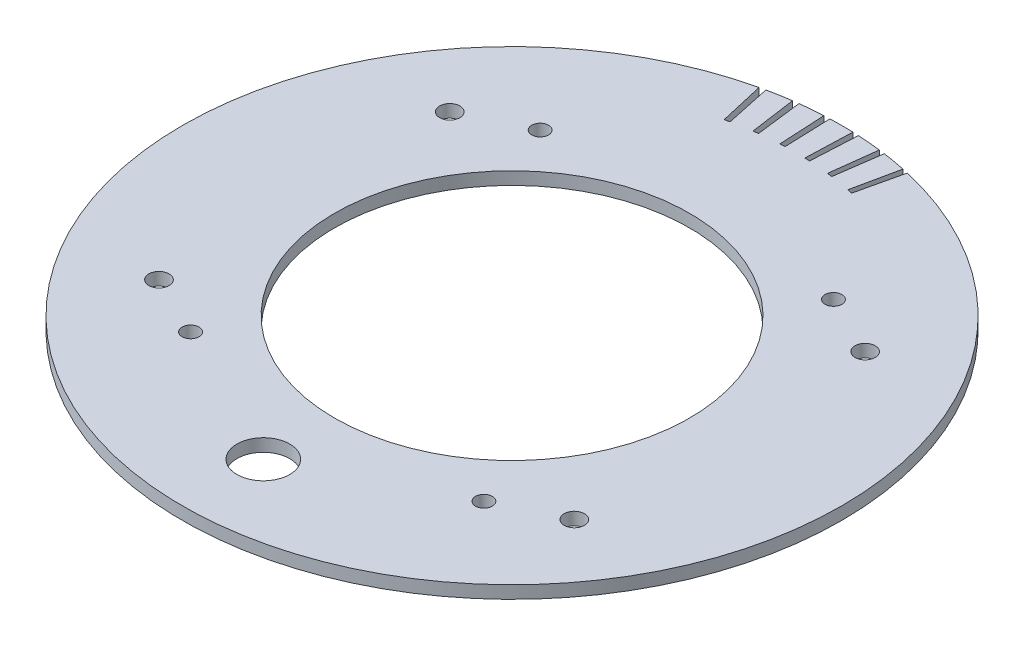
from build123d import *

# Parameters (mm, degrees)
F_98MM_6ID_CENTERING_RING_SKETCH_R = 53.34
CENTERING_RING_EXTRUDE_DEPTH       = 1.905
CENTERING_RING_EXTRUDE_DEPTH_BACK  = 1.905
CUT_EXTRUDE3_DEPTH                 = 4.81
CIRPATTERN1_COUNT                  = 6
CIRPATTERN1_ANGLE                  = 25
SKETCH5_R                          = 3.048
SKETCH5_R_2                        = 2.54
SKETCH5_R_3                        = 7.9375
CUT_EXTRUDE4_DEPTH                 = 3.81


with BuildPart() as part:
    # 98mm - 6ID centering ring sketch → Centering Ring Extrude (new body, two sides)
    with BuildSketch(Plane(origin=(0, 0, 0), x_dir=(1, 0, 0), z_dir=(0, 1, 0))) as centering_ring_extrude_sk:
        with BuildLine():
            Line((56.425744124, 3.175), (99.009105516, 3.175))
            ThreePointArc((99.009105516, 3.175), (70.045997744, 70.045997744), (3.175, 99.009105516))
            Line((3.175, 99.009105516), (3.175, 56.425744124))
            ThreePointArc((3.175, 56.425744124), (0, 56.515), (-3.175, 56.425744124))
            Line((-3.175, 56.425744124), (-3.175, 99.009105516))
            ThreePointArc((-3.175, 99.009105516), (-70.045997744, 70.045997744), (-99.009105516, 3.175))
            Line((-99.009105516, 3.175), (-56.425744124, 3.175))
            ThreePointArc((-56.425744124, 3.175), (-56.515, 0), (-56.425744124, -3.175))
            Line((-56.425744124, -3.175), (-99.009105516, -3.175))
            ThreePointArc((-99.009105516, -3.175), (-70.045997744, -70.045997744), (-3.175, -99.009105516))
            Line((-3.175, -99.009105516), (-3.175, -56.425744124))
            ThreePointArc((-3.175, -56.425744124), (0, -56.515), (3.175, -56.425744124))
            Line((3.175, -56.425744124), (3.175, -99.009105516))
            ThreePointArc((3.175, -99.009105516), (70.045997744, -70.045997744), (99.009105516, -3.175))
            Line((99.009105516, -3.175), (56.425744124, -3.175))
            ThreePointArc((56.425744124, -3.175), (56.515, 0), (56.425744124, 3.175))
        make_face()
        Circle(F_98MM_6ID_CENTERING_RING_SKETCH_R, mode=Mode.SUBTRACT)
        with BuildLine():
            ThreePointArc((99.06, 0), (99.047275562, 1.587703943), (99.009105516, 3.175))
            Line((99.009105516, 3.175), (56.425744124, 3.175))
            ThreePointArc((56.425744124, 3.175), (56.515, 0), (56.425744124, -3.175))
            Line((56.425744124, -3.175), (99.009105516, -3.175))
            ThreePointArc((99.009105516, -3.175), (99.047275562, -1.587703943), (99.06, 0))
        make_face()
        with BuildLine():
            Line((3.175, 56.425744124), (3.175, 99.009105516))
            ThreePointArc((3.175, 99.009105516), (0, 99.06), (-3.175, 99.009105516))
            Line((-3.175, 99.009105516), (-3.175, 56.425744124))
            ThreePointArc((-3.175, 56.425744124), (0, 56.515), (3.175, 56.425744124))
        make_face()
        with BuildLine():
            Line((-56.425744124, 3.175), (-99.009105516, 3.175))
            ThreePointArc((-99.009105516, 3.175), (-99.06, 0), (-99.009105516, -3.175))
            Line((-99.009105516, -3.175), (-56.425744124, -3.175))
            ThreePointArc((-56.425744124, -3.175), (-56.515, 0), (-56.425744124, 3.175))
        make_face()
        with BuildLine():
            ThreePointArc((-3.175, -99.009105516), (0, -99.06), (3.175, -99.009105516))
            Line((3.175, -99.009105516), (3.175, -56.425744124))
            ThreePointArc((3.175, -56.425744124), (0, -56.515), (-3.175, -56.425744124))
            Line((-3.175, -56.425744124), (-3.175, -99.009105516))
        make_face()
    extrude(amount=CENTERING_RING_EXTRUDE_DEPTH)
    extrude(centering_ring_extrude_sk.sketch, amount=-CENTERING_RING_EXTRUDE_DEPTH_BACK)

    # Sketch3 → Cut-Extrude3 (cut, through all)
    with BuildSketch(Plane(origin=(0, 1.905, 0), x_dir=(1, 0, 0), z_dir=(0, 1, 0))):
        with BuildLine():
            Line((-22.283651443, 96.521098618), (-19.141085214, 82.909148813))
            ThreePointArc((-19.141085214, 82.909148813), (-18.41684675, 83.073027246), (-17.691205772, 83.230579346))
            Line((-17.691205772, 83.230579346), (-20.595732092, 96.895301329))
            ThreePointArc((-20.595732092, 96.895301329), (-21.440508157, 96.711882465), (-22.283651443, 96.521098618))
        make_face()
    cut_extrude3 = extrude(amount=-CUT_EXTRUDE3_DEPTH, mode=Mode.SUBTRACT)

    # CirPattern1: Cut-Extrude3 ×6 about axis
    cirpattern1_axis = Axis((0, 0, 0), (0, -1, 0))
    for i in range(1, CIRPATTERN1_COUNT):
        add(cut_extrude3.rotate(cirpattern1_axis, i * CIRPATTERN1_ANGLE / (CIRPATTERN1_COUNT - 1)), mode=Mode.SUBTRACT)

    # Sketch5 → Cut-Extrude4 (cut)
    with BuildSketch(Plane.XZ.offset(1.905)):
        with Locations((-62.419385775, 43.70652445)):
            Circle(SKETCH5_R)
        with Locations((-44.082374272, 52.535327909)):
            Circle(SKETCH5_R_2)
        with Locations((44.082374272, 52.535327909)):
            Circle(SKETCH5_R_2)
        with Locations((62.419385775, 43.70652445)):
            Circle(SKETCH5_R)
        with Locations((62.419385775, -43.70652445)):
            Circle(SKETCH5_R)
        with Locations((44.082374272, -52.535327909)):
            Circle(SKETCH5_R_2)
        with Locations((-44.082374272, -52.535327909)):
            Circle(SKETCH5_R_2)
        with Locations((-62.419385775, -43.70652445)):
            Circle(SKETCH5_R)
        with Locations((0, 74.75474)):
            Circle(SKETCH5_R_3)
    extrude(amount=-CUT_EXTRUDE4_DEPTH, mode=Mode.SUBTRACT)


solid = part.part
